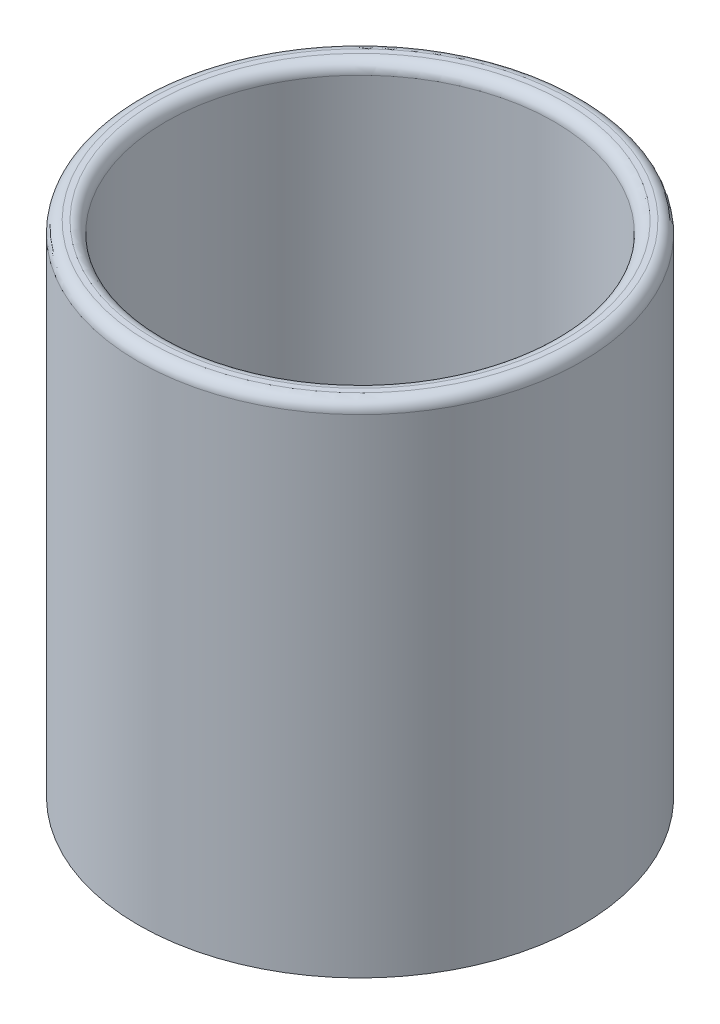
from build123d import *

# Parameters (mm, degrees)
SKETCH1_R           = 40
BOSS_EXTRUDE1_DEPTH = 90
SKETCH2_R           = 35
CUT_EXTRUDE1_DEPTH  = 85
FILLET1_R           = 2
FILLET2_R           = 2
FILLET4_R           = 5


with BuildPart() as part:
    # Sketch1 → Boss-Extrude1 (new body)
    with BuildSketch(Plane(origin=(0, 0, 0), x_dir=(1, 0, 0), z_dir=(0, 1, 0))):
        Circle(SKETCH1_R)
    extrude(amount=BOSS_EXTRUDE1_DEPTH)

    # Sketch2 → Cut-Extrude1 (cut)
    with BuildSketch(Plane(origin=(0, 90, 0), x_dir=(1, 0, 0), z_dir=(0, 1, 0))):
        Circle(SKETCH2_R)
    extrude(amount=-CUT_EXTRUDE1_DEPTH, mode=Mode.SUBTRACT)

    # Fillet1
    fillet1_edges = [part.edges().sort_by_distance(p)[0] for p in [
        (-40, 90, 0),
    ]]
    fillet(fillet1_edges, radius=FILLET1_R)

    # Fillet2
    fillet2_edges = [part.edges().sort_by_distance(p)[0] for p in [
        (-35, 90, 0),
    ]]
    fillet(fillet2_edges, radius=FILLET2_R)

    # Fillet4
    fillet4_edges = [part.edges().sort_by_distance(p)[0] for p in [
        (-35, 5, 0),
    ]]
    fillet(fillet4_edges, radius=FILLET4_R)


solid = part.part
